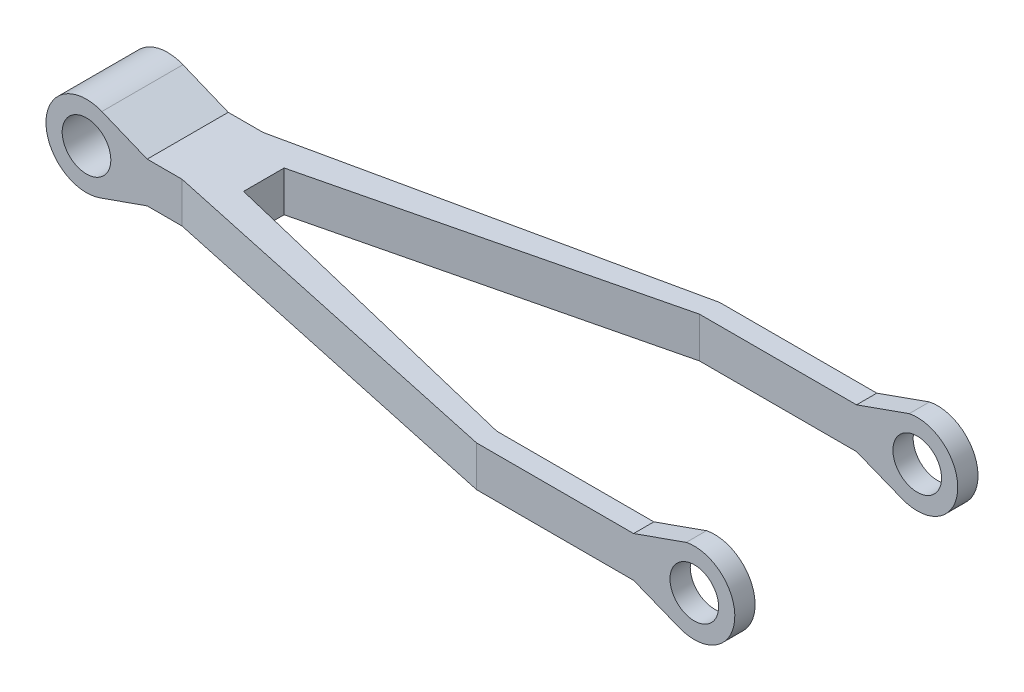
from build123d import *

# Parameters (mm, degrees)
BOSS_EXTRUDE1_DEPTH = 300
SKETCH3_OUTSIDE_W   = 1151.978
SKETCH3_OUTSIDE_H   = 502.25
CUT_EXTRUDE1_DEPTH  = 300
CUT_EXTRUDE3_DEPTH  = 300
SKETCH6_R           = 30
CUT_EXTRUDE4_DEPTH  = 200


with BuildPart() as part:
    # Sketch1 → Boss-Extrude1 (new body)
    with BuildSketch(Plane.XY):
        with BuildLine():
            Line((350.126678984, 24.643496119), (-349.873321016, 24.643496119))
            Line((-349.873321016, 24.643496119), (-405.7801007, 47.538028277))
            ThreePointArc((-405.7801007, 47.538028277), (-474.713018176, 2.509970806), (-408.102340797, -45.887247404))
            Line((-408.102340797, -45.887247404), (-349.873321016, -25.356503881))
            Line((-349.873321016, -25.356503881), (350.126678984, -25.356503881))
            Line((350.126678984, -25.356503881), (406.56125394, -47.746215249))
            ThreePointArc((406.56125394, -47.746215249), (474.7986376, -5.753101083), (415.157857426, 47.751473547))
            Line((415.157857426, 47.751473547), (401.702587644, 42.970319678))
            Line((401.702587644, 42.970319678), (350.126678984, 24.643496119))
        make_face()
    extrude(amount=BOSS_EXTRUDE1_DEPTH)

    # Sketch3 outside → Cut-Extrude1 (cut)
    with BuildSketch(Plane(origin=(0, 24.643496119, 0), x_dir=(1, 0, 0), z_dir=(0, 1, 0))):
        with Locations((0.136, -150)):
            Rectangle(SKETCH3_OUTSIDE_W, SKETCH3_OUTSIDE_H)
        Polygon((156.384680345, -275), (-255.951397242, -175), (-255.951397242, -150), (-255.951397242, -125), (156.384680345, -25), (646.790959518, -25), (660.003845731, 0), (156.384680345, 0), (-306.817002614, -100), (-623.605485165, -100), (-623.605485165, -200), (-306.817002614, -200), (156.384680345, -300), (568.093933709, -300), (523.266387174, -275), align=None, mode=Mode.SUBTRACT)
    extrude(amount=-CUT_EXTRUDE1_DEPTH, mode=Mode.SUBTRACT)

    # Sketch5 → Cut-Extrude3 (cut)
    with BuildSketch(Plane(origin=(0, 24.643496119, 0), x_dir=(1, 0, 0), z_dir=(0, 1, 0))):
        Polygon((156.384680345, -25), (555.921134312, -25), (555.921134312, -275), (156.384680345, -275), (-255.951397242, -175), (-255.951397242, -125), align=None)
        Polygon((-349.873321016, -100), (-477.733615617, -100), (-477.733615617, 50.340527991), (-332.07706739, 50.340527991), align=None)
        Polygon((-349.873321016, -200), (-349.873321016, -364.123748435), (-511.890412396, -324.647411731), (-481.519399358, -200), align=None)
    extrude(amount=CUT_EXTRUDE3_DEPTH, mode=Mode.SUBTRACT)

    # Sketch6 → Cut-Extrude4 (cut, symmetric)
    with BuildSketch(Plane.XY.offset(200)):
        with Locations((-424.728457358, 1.267521688)):
            Circle(SKETCH6_R)
        with Locations((425, -1.27027907)):
            Circle(SKETCH6_R)
    extrude(amount=CUT_EXTRUDE4_DEPTH, both=True, mode=Mode.SUBTRACT)


solid = part.part
